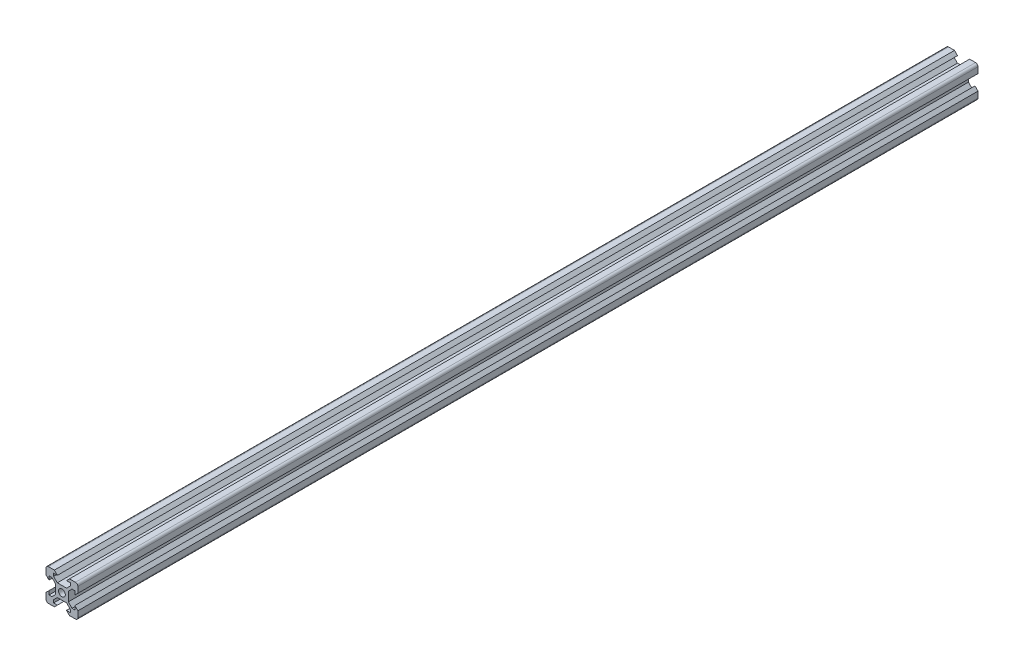
from build123d import *

# Parameters (mm, degrees)
SKETCH1_R           = 2.125
BOSS_EXTRUDE1_DEPTH = 565


with BuildPart() as part:
    # Sketch1 → Boss-Extrude1 (new body)
    with BuildSketch(Plane.XY):
        with BuildLine():
            Line((8.1, 5.225), (8.1, 2.85))
            Line((8.1, 2.85), (10, 4.75))
            Line((10, 4.75), (10, 8.5))
            ThreePointArc((10, 8.5), (9.560660172, 9.560660172), (8.5, 10))
            Line((8.5, 10), (4.75, 10))
            Line((4.75, 10), (2.85, 8.1))
            Line((2.85, 8.1), (5.225, 8.1))
            Line((5.225, 8.1), (5.225, 6.325))
            Line((5.225, 6.325), (2.9, 4))
            Line((2.9, 4), (-2.9, 4))
            Line((-2.9, 4), (-5.225, 6.325))
            Line((-5.225, 6.325), (-5.225, 8.1))
            Line((-5.225, 8.1), (-2.85, 8.1))
            Line((-2.85, 8.1), (-4.75, 10))
            Line((-4.75, 10), (-8.5, 10))
            ThreePointArc((-8.5, 10), (-9.560660172, 9.560660172), (-10, 8.5))
            Line((-10, 8.5), (-10, 4.75))
            Line((-10, 4.75), (-8.1, 2.85))
            Line((-8.1, 2.85), (-8.1, 5.225))
            Line((-8.1, 5.225), (-6.325, 5.225))
            Line((-6.325, 5.225), (-4, 2.9))
            Line((-4, 2.9), (-4, -2.9))
            Line((-4, -2.9), (-6.325, -5.225))
            Line((-6.325, -5.225), (-8.1, -5.225))
            Line((-8.1, -5.225), (-8.1, -2.85))
            Line((-8.1, -2.85), (-10, -4.75))
            Line((-10, -4.75), (-10, -8.5))
            ThreePointArc((-10, -8.5), (-9.560660172, -9.560660172), (-8.5, -10))
            Line((-8.5, -10), (-4.75, -10))
            Line((-4.75, -10), (-2.85, -8.1))
            Line((-2.85, -8.1), (-5.225, -8.1))
            Line((-5.225, -8.1), (-5.225, -6.325))
            Line((-5.225, -6.325), (-2.9, -4))
            Line((-2.9, -4), (2.9, -4))
            Line((2.9, -4), (5.225, -6.325))
            Line((5.225, -6.325), (5.225, -8.1))
            Line((5.225, -8.1), (2.85, -8.1))
            Line((2.85, -8.1), (4.75, -10))
            Line((4.75, -10), (8.5, -10))
            ThreePointArc((8.5, -10), (9.560660172, -9.560660172), (10, -8.5))
            Line((10, -8.5), (10, -4.75))
            Line((10, -4.75), (8.1, -2.85))
            Line((8.1, -2.85), (8.1, -5.225))
            Line((8.1, -5.225), (6.325, -5.225))
            Line((6.325, -5.225), (4, -2.9))
            Line((4, -2.9), (4, 2.9))
            Line((4, 2.9), (6.325, 5.225))
            Line((6.325, 5.225), (8.1, 5.225))
        make_face()
        Circle(SKETCH1_R, mode=Mode.SUBTRACT)
    extrude(amount=BOSS_EXTRUDE1_DEPTH)


solid = part.part
